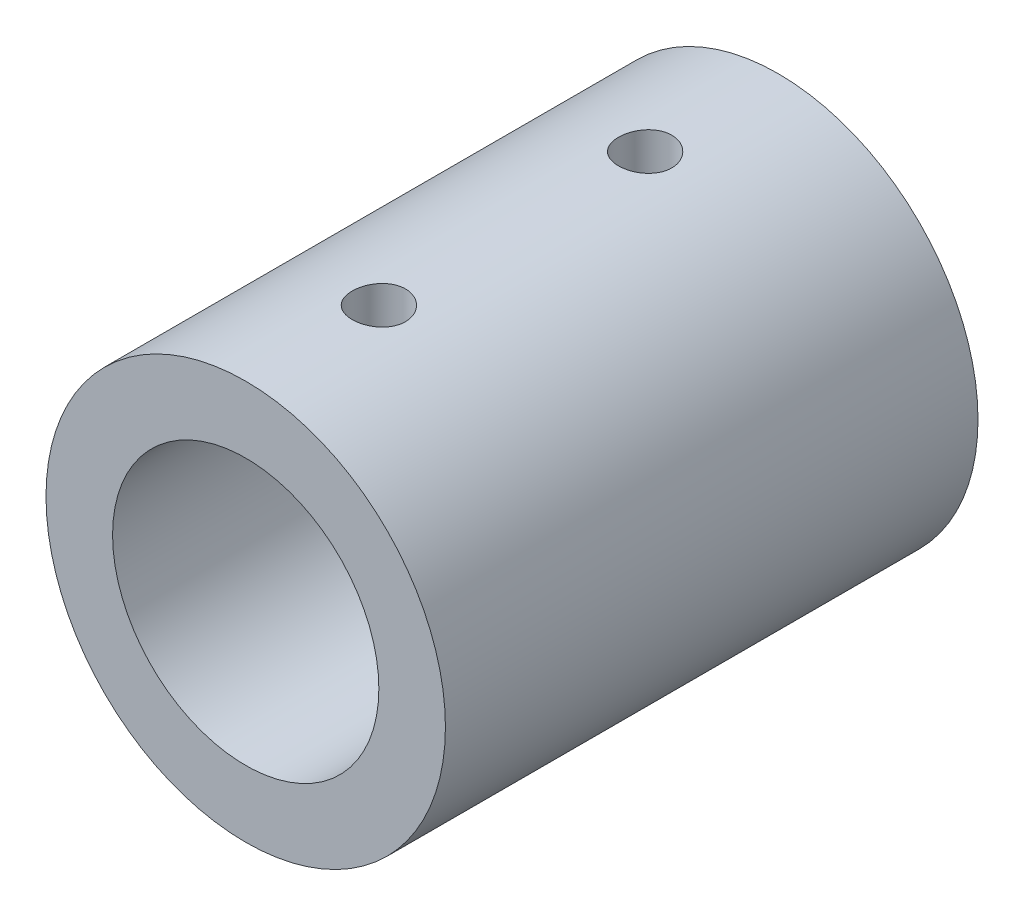
from build123d import *

# Parameters (mm, degrees)
BOSS_EXTRUDE1_DEPTH      = 30
BOSS_EXTRUDE1_DEPTH_BACK = 30
SKETCH1_R                = 22.5
SKETCH1_R_2              = 15
SKETCH2_R                = 3
CUT_EXTRUDE1_DEPTH       = 30


with BuildPart() as part:
    # Sketch1 → Boss-Extrude1 (new, two sides: drawn at the far end of the back side and taken through both)
    with BuildSketch(Plane.XY.offset(-BOSS_EXTRUDE1_DEPTH_BACK)):
        Circle(SKETCH1_R)
        Circle(SKETCH1_R_2, mode=Mode.SUBTRACT)
    extrude(amount=BOSS_EXTRUDE1_DEPTH + BOSS_EXTRUDE1_DEPTH_BACK)

    # Sketch2 → Cut-Extrude1 (cut)
    with BuildSketch(Plane(origin=(0, 0, 0), x_dir=(1, 0, 0), z_dir=(0, 1, 0))):
        with Locations((0, -15)):
            Circle(SKETCH2_R)
    cut_extrude1 = extrude(amount=CUT_EXTRUDE1_DEPTH, mode=Mode.SUBTRACT)

    # Mirror1: Cut-Extrude1 across plane
    add(cut_extrude1.mirror(Plane.XY), mode=Mode.SUBTRACT)


solid = part.part
